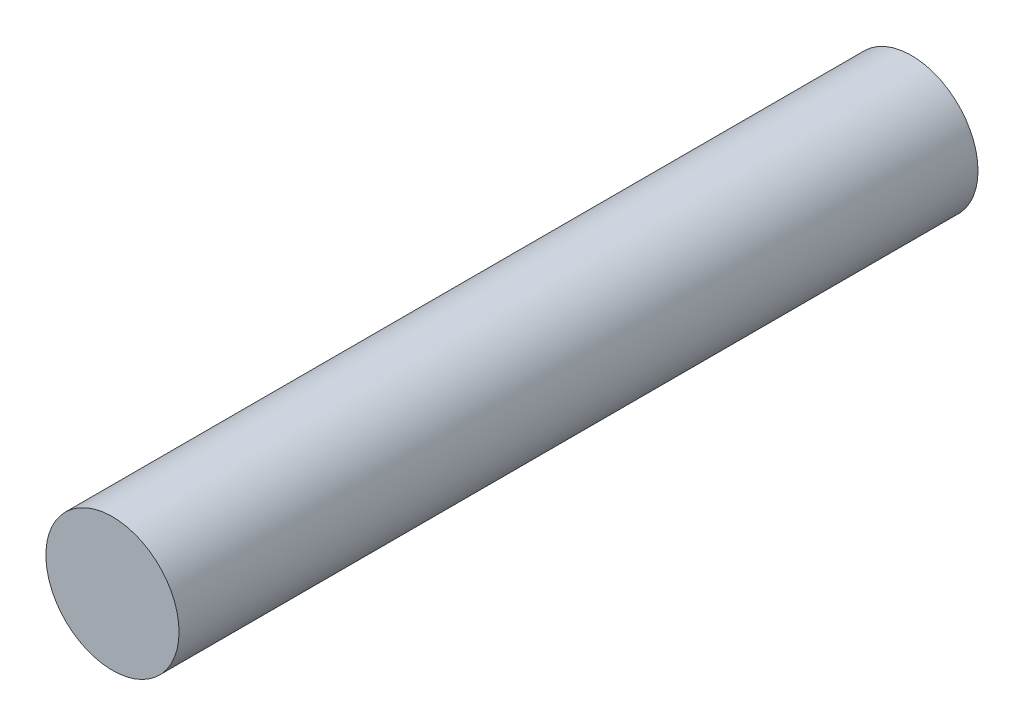
from build123d import *

# Parameters (mm, degrees)
SKETCH1_R           = 1.5
BOSS_EXTRUDE1_DEPTH = 18


with BuildPart() as part:
    # Sketch1 → Boss-Extrude1 (new body)
    with BuildSketch(Plane.XY):
        Circle(SKETCH1_R)
    extrude(amount=BOSS_EXTRUDE1_DEPTH)


solid = part.part
